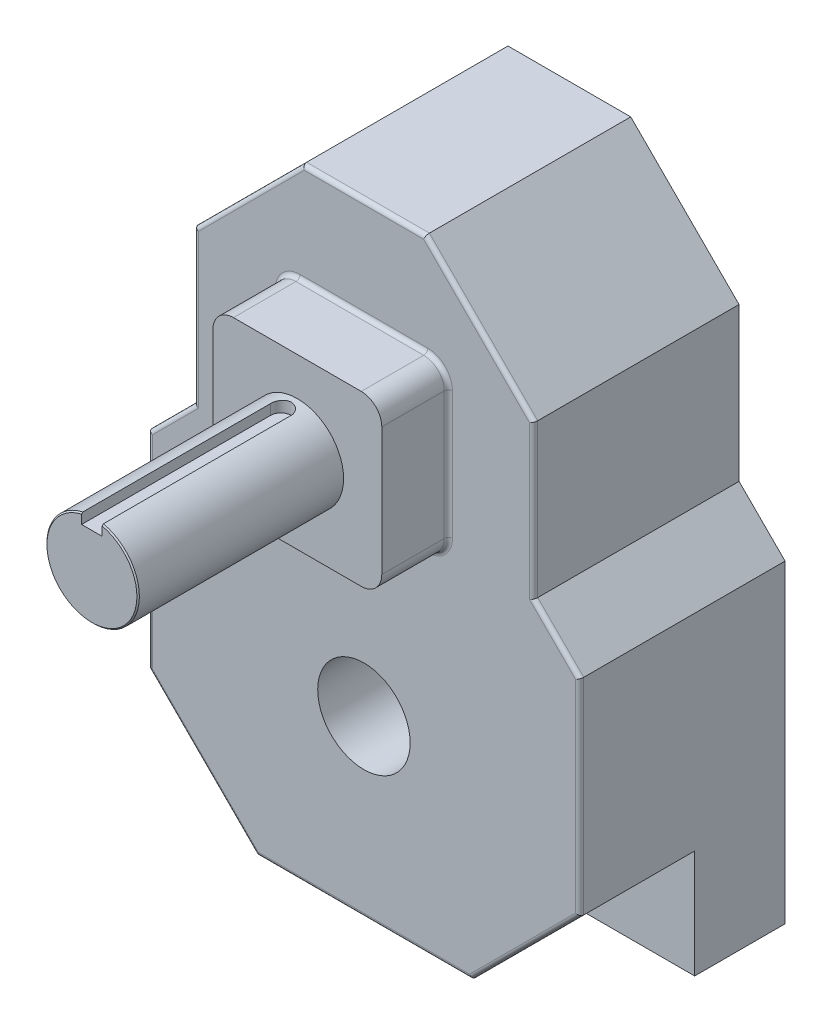
from build123d import *

# Parameters (mm, degrees)
BOSS_EXTRUDE1_DEPTH = 63.5
SKETCH3_W           = 52.197
SKETCH3_H           = 52.197
BOSS_EXTRUDE2_DEPTH = 20.574
SKETCH_D_R          = 14.2875
BOSS_EXTRUDE3_DEPTH = 63.5
CUT_EXTRUDE1_DEPTH  = 35.56
FILLET1_R           = 6.35
FILLET2_R           = 1.27
KEYWAY_START        = 10.7569
KEYWAY_DEPTH        = 47.3931
CHAMFER1_SIZE       = 0.381
SKETCH7_R           = 14.2875
CUT_EXTRUDE3_DEPTH  = 148.574


with BuildPart() as part:
    # L,M → Boss-Extrude1 (new body)
    with BuildSketch(Plane.XY):
        Polygon((-66.675, 53.975), (66.675, 53.975), (66.675, 151.07969491), (52.451, 165.30369491), (52.451, 212.64830509), (18.97330509, 246.126), (-18.97330509, 246.126), (-52.451, 212.64830509), (-52.451, 165.30369491), (-66.675, 151.07969491), align=None)
    extrude(amount=BOSS_EXTRUDE1_DEPTH)

    # Sketch3 → Boss-Extrude2 (add)
    with BuildSketch(Plane.XY.offset(63.5)):
        with Locations((0, 188.976)):
            Rectangle(SKETCH3_W, SKETCH3_H)
    extrude(amount=BOSS_EXTRUDE2_DEPTH)

    # D → Boss-Extrude3 (add)
    with BuildSketch(Plane.XY.offset(84.074)):
        with Locations((0, 188.976)):
            Circle(SKETCH_D_R)
    extrude(amount=BOSS_EXTRUDE3_DEPTH)

    # Sketch5 → Cut-Extrude1 (cut)
    with BuildSketch(Plane.XY.offset(63.5)):
        Polygon((66.675, 87.45269491), (33.19730509, 53.975), (66.675, 53.975), align=None)
        Polygon((-66.675, 53.975), (-66.675, 87.45269491), (-33.19730509, 53.975), align=None)
    extrude(amount=-CUT_EXTRUDE1_DEPTH, mode=Mode.SUBTRACT)

    # Fillet1
    fillet1_edges = [part.edges().sort_by_distance(p)[0] for p in [
        (-26.0985, 215.0745, 73.787),
        (-26.0985, 162.8775, 73.787),
        (26.0985, 162.8775, 73.787),
        (26.0985, 215.0745, 73.787),
    ]]
    fillet(fillet1_edges, radius=FILLET1_R)

    # Fillet2
    fillet2_edges = [part.edges().sort_by_distance(p)[0] for p in [
        (66.675, 119.26619491, 63.5),
        (49.936152545, 70.713847455, 63.5),
        (59.563, 158.19169491, 63.5),
        (52.451, 188.976, 63.5),
        (35.712152545, 229.387152545, 63.5),
        (0, 53.975, 63.5),
        (0, 246.126, 63.5),
        (-35.712152545, 229.387152545, 63.5),
        (-52.451, 188.976, 63.5),
        (-59.563, 158.19169491, 63.5),
        (-66.675, 119.26619491, 63.5),
        (-49.936152545, 70.713847455, 63.5),
        (0, 162.8775, 63.5),
        (-26.0985, 188.976, 63.5),
        (26.0985, 188.976, 63.5),
        (0, 215.0745, 63.5),
        (-24.238628061, 164.737371939, 63.5),
        (24.238628061, 164.737371939, 63.5),
        (-24.238628061, 213.214628061, 63.5),
        (24.238628061, 213.214628061, 63.5),
    ]]
    fillet(fillet2_edges, radius=FILLET2_R)

    # Sketch6 → Keyway (cut, through all)
    with BuildSketch(Plane(origin=(0, 188.976, 0), x_dir=(-1, 0, 0), z_dir=(0, 1, 0)).offset(KEYWAY_START)):
        with BuildLine():
            Line((3.175, 147.574), (3.175, 89.154))
            ThreePointArc((3.175, 89.154), (0, 85.979), (-3.175, 89.154))
            Line((-3.175, 89.154), (-3.175, 147.574))
            ThreePointArc((-3.175, 147.574), (0, 150.749), (3.175, 147.574))
        make_face()
    extrude(amount=KEYWAY_DEPTH, mode=Mode.SUBTRACT)

    # Chamfer1
    chamfer1_edges = [part.edges().sort_by_distance(p)[0] for p in [
        (-8.909821652, 177.806947472, 147.574),
    ]]
    chamfer(chamfer1_edges, length=CHAMFER1_SIZE)

    # Sketch7 → Cut-Extrude3 (cut, through all)
    with BuildSketch(Plane(origin=(0, 0, 0), x_dir=(-1, 0, 0), z_dir=(0, 0, -1))):
        with Locations((0, 107.95)):
            Circle(SKETCH7_R)
    extrude(amount=-CUT_EXTRUDE3_DEPTH, mode=Mode.SUBTRACT)


solid = part.part
